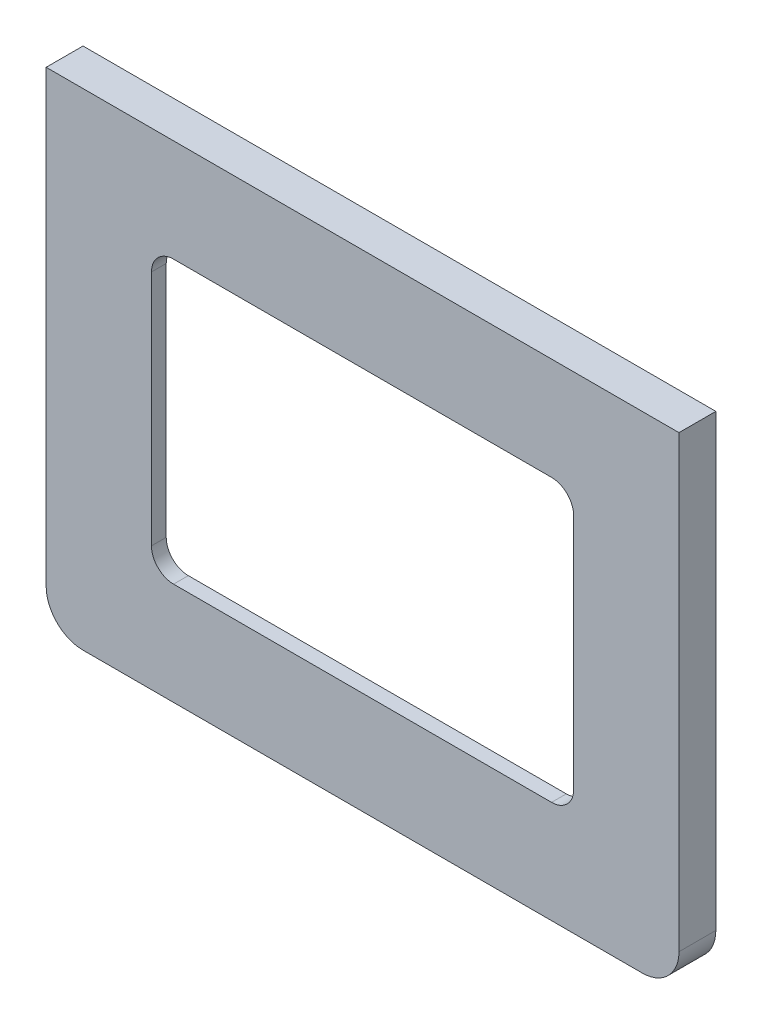
from build123d import *

# Parameters (mm, degrees)
SKETCH1_W           = 85.87
SKETCH1_H           = 66
BOSS_EXTRUDE2_DEPTH = 5
FILLET1_R           = 5
CUT_EXTRUDE2_DEPTH  = 3
CUT_EXTRUDE1_REACH  = 7
SKETCH2_W           = 57.29
SKETCH2_H           = 38.19
FILLET2_R           = 3
SKETCH3_R           = 1.5
BOSS_EXTRUDE3_DEPTH = 3


with BuildPart() as part:
    # Sketch1 → Boss-Extrude2 (new body)
    with BuildSketch(Plane.XY):
        with Locations((39.935, 30)):
            Rectangle(SKETCH1_W, SKETCH1_H)
    extrude(amount=BOSS_EXTRUDE2_DEPTH)

    # Fillet1
    fillet1_edges = [part.edges().sort_by_distance(p)[0] for p in [
        (82.87, -3, 2.5),
        (-3, -3, 2.5),
    ]]
    fillet(fillet1_edges, radius=FILLET1_R)

    # Sketch4 → Cut-Extrude2 (cut)
    with BuildSketch(Plane(origin=(0, 0, 0), x_dir=(-1, 0, 0), z_dir=(0, 0, -1))):
        with BuildLine():
            Line((-80.87, 61), (-80.87, 2))
            ThreePointArc((-80.87, 2), (-79.991320344, -0.121320344), (-77.87, -1))
            Line((-77.87, -1), (-2, -1))
            ThreePointArc((-2, -1), (0.121320344, -0.121320344), (1, 2))
            Line((1, 2), (1, 61))
            Line((1, 61), (-80.87, 61))
        make_face()
    extrude(amount=-CUT_EXTRUDE2_DEPTH, mode=Mode.SUBTRACT)

    # Sketch2 → Cut-Extrude1 (cut, up to next)
    with BuildSketch(Plane.XY.offset(5), mode=Mode.PRIVATE) as cut_extrude1_sk1:
        with Locations((39.935, 30)):
            Rectangle(SKETCH2_W, SKETCH2_H)
    cut_extrude1_tool1 = extrude(cut_extrude1_sk1.sketch, amount=-CUT_EXTRUDE1_REACH, mode=Mode.PRIVATE) & part.part
    add(cut_extrude1_tool1.solids().sort_by_distance((39.935, 30, 5))[0], mode=Mode.SUBTRACT)

    # Fillet2
    fillet2_edges = [part.edges().sort_by_distance(p)[0] for p in [
        (11.29, 10.905, 4),
        (11.29, 49.095, 4),
        (68.58, 49.095, 4),
        (68.58, 10.905, 4),
    ]]
    fillet(fillet2_edges, radius=FILLET2_R)

    # Sketch3 → Boss-Extrude3 (add)
    with BuildSketch(Plane(origin=(0, 0, 3), x_dir=(-1, 0, 0), z_dir=(0, 0, -1))):
        with Locations((-4, 4)):
            Circle(SKETCH3_R)
        with Locations((-4, 56)):
            Circle(SKETCH3_R)
        with Locations((-70.3, 56)):
            Circle(SKETCH3_R)
        with Locations((-70.3, 4)):
            Circle(SKETCH3_R)
    extrude(amount=BOSS_EXTRUDE3_DEPTH)


solid = part.part
